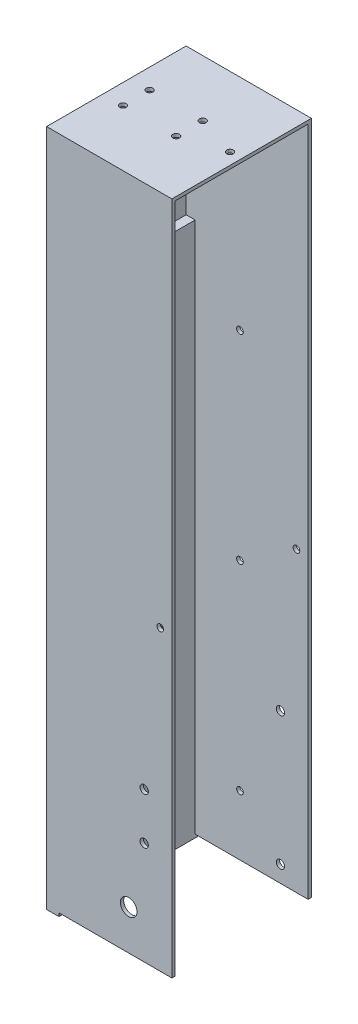
from build123d import *

# Parameters (mm, degrees)
SKETCH1_W            = 42
SKETCH1_H            = 170
BOSS_EXTRUDE1_DEPTH  = 1
SKETCH2_W            = 1
SKETCH2_H            = 170
BOSS_EXTRUDE2_DEPTH  = 50
BOSS_EXTRUDE3_DEPTH  = 30
SKETCH5_W            = 1
SKETCH5_H            = 1
CUT_EXTRUDE1_DEPTH   = 170
SKETCH6_W            = 1
SKETCH6_H            = 1
CUT_EXTRUDE2_DEPTH   = 170
SKETCH9_R            = 1.5
CUT_EXTRUDE3_DEPTH   = 10
SKETCH10_R           = 1.5
CUT_EXTRUDE4_DEPTH   = 10
SKETCH11_R           = 2.028327886
BOSS_EXTRUDE4_DEPTH  = 1
SKETCH13_W           = 40
SKETCH13_H           = 22.9
BOSS_EXTRUDE5_DEPTH  = 50
SKETCH14_W           = 42
SKETCH14_H           = 21.9
CUT_EXTRUDE6_DEPTH   = 60
SKETCH17_R           = 1
CUT_EXTRUDE7_DEPTH   = 10
SKETCH18_W           = 40
SKETCH18_H           = 1
SKETCH18_W_2         = 36
SKETCH18_W_3         = 13
SKETCH18_W_4         = 9
BOSS_EXTRUDE7_DEPTH  = 1
SKETCH19_W           = 1
SKETCH19_H           = 42
BOSS_EXTRUDE8_DEPTH  = 1
SKETCH20_W           = 1.000149207
SKETCH20_H           = 1
CUT_EXTRUDE8_DEPTH   = 1
SKETCH21_W           = 1
SKETCH21_H           = 1
CUT_EXTRUDE9_DEPTH   = 1
BOSS_EXTRUDE9_REACH  = 44
SKETCH22_W           = 1
SKETCH22_H           = 31
SKETCH26_W           = 11.5
SKETCH26_H           = 42
BOSS_EXTRUDE13_DEPTH = 1
SKETCH35_W           = 40
SKETCH35_H           = 31
CUT_EXTRUDE17_DEPTH  = 27
SKETCH36_W           = 42
SKETCH36_H           = 1
CUT_EXTRUDE18_DEPTH  = 24
SKETCH37_W           = 12
SKETCH37_H           = 212.744224338
CUT_EXTRUDE19_DEPTH  = 50
SKETCH39_R           = 1.25
CUT_EXTRUDE20_DEPTH  = 10
SKETCH40_R           = 1.25
CUT_EXTRUDE21_DEPTH  = 10
SKETCH41_R           = 2.590750915
BOSS_EXTRUDE14_DEPTH = 1
SKETCH42_R           = 1.25
CUT_EXTRUDE22_DEPTH  = 1
SKETCH43_R           = 1.25
CUT_EXTRUDE23_DEPTH  = 1
SKETCH44_R           = 6.392169631
BOSS_EXTRUDE16_DEPTH = 1
SKETCH45_R           = 1.25
CUT_EXTRUDE24_DEPTH  = 1
SKETCH46_W           = 1.29
SKETCH46_H           = 42
CUT_EXTRUDE25_DEPTH  = 190
SKETCH47_W           = 1
SKETCH47_H           = 42
BOSS_EXTRUDE17_DEPTH = 179.1
SKETCH48_W           = 37.71
SKETCH48_H           = 0.1
CUT_EXTRUDE26_DEPTH  = 179.1
SKETCH50_W           = 10
SKETCH50_H           = 120
BOSS_EXTRUDE20_DEPTH = 4
SKETCH52_W           = 28
SKETCH52_H           = 1
SKETCH52_W_2         = 24
BOSS_EXTRUDE21_DEPTH = 0.1
BOSS_EXTRUDE22_DEPTH = 0.1
SKETCH54_W           = 10
SKETCH54_H           = 120.1
BOSS_EXTRUDE23_DEPTH = 3.71
SKETCH55_W           = 4.2
SKETCH55_H           = 42
BOSS_EXTRUDE24_DEPTH = 1
SKETCH56_W           = 0.49
SKETCH56_H           = 42
CUT_EXTRUDE27_DEPTH  = 1
SKETCH58_R           = 1
CUT_EXTRUDE28_DEPTH  = 1
SKETCH59_R           = 1.868831557
BOSS_EXTRUDE25_DEPTH = 1
SKETCH60_R           = 1
CUT_EXTRUDE29_DEPTH  = 1
SKETCH61_R           = 1
CUT_EXTRUDE30_DEPTH  = 1
SKETCH62_W           = 5.426939544
SKETCH62_H           = 172.64225577
BOSS_EXTRUDE26_DEPTH = 1
SKETCH63_W           = 5.574315559
SKETCH63_H           = 175.575200823
BOSS_EXTRUDE27_DEPTH = 1
SKETCH64_W           = 3.71
SKETCH64_H           = 42
BOSS_EXTRUDE29_DEPTH = 121.1
SKETCH66_R           = 1
CUT_EXTRUDE31_DEPTH  = 43
SKETCH67_R           = 1
CUT_EXTRUDE32_DEPTH  = 1
SKETCH68_R           = 2.5
CUT_EXTRUDE33_DEPTH  = 10
SKETCH71_R           = 1
CUT_EXTRUDE35_DEPTH  = 10
SKETCH72_W           = 37.71
SKETCH72_H           = 20
BOSS_EXTRUDE30_DEPTH = 42
SKETCH73_R           = 1
CUT_EXTRUDE36_DEPTH  = 42
SKETCH74_W           = 40
SKETCH74_H           = 20
CUT_EXTRUDE38_DEPTH  = 36.71
SKETCH75_W           = 37.71
SKETCH75_H           = 4
BOSS_EXTRUDE31_DEPTH = 42
SKETCH76_R           = 1
CUT_EXTRUDE39_DEPTH  = 42
SKETCH77_W           = 40
SKETCH77_H           = 4
CUT_EXTRUDE40_DEPTH  = 36.71
BOSS_EXTRUDE32_DEPTH = 40
CUT_EXTRUDE41_DEPTH  = 5
CUT_EXTRUDE42_DEPTH  = 5
SKETCH81_R           = 1
CUT_EXTRUDE43_DEPTH  = 9.71
SKETCH82_R           = 1
CUT_EXTRUDE44_DEPTH  = 9.71


with BuildPart() as part:
    # Sketch1 → Boss-Extrude1 (new body)
    with BuildSketch(Plane(origin=(0, 0, 0), x_dir=(0, 0, -1), z_dir=(1, 0, 0))):
        with Locations((7.169014085, -74.911791253)):
            Rectangle(SKETCH1_W, SKETCH1_H)
    extrude(amount=BOSS_EXTRUDE1_DEPTH)

    # Sketch2 → Boss-Extrude2 (add)
    with BuildSketch(Plane(origin=(1, 0, 0), x_dir=(0, 0, -1), z_dir=(1, 0, 0))):
        with Locations((27.669014085, -74.911791253)):
            Rectangle(SKETCH2_W, SKETCH2_H)
        with Locations((-13.330985915, -74.911791253)):
            Rectangle(SKETCH2_W, SKETCH2_H)
    extrude(amount=BOSS_EXTRUDE2_DEPTH)

    # Sketch4 → Boss-Extrude3 (add)
    with BuildSketch(Plane(origin=(0, 10.088208747, 0), x_dir=(1, 0, 0), z_dir=(0, 1, 0))):
        Polygon((51, 28.169014085), (51, 27.169014085), (1, 27.169014085), (1, -12.830985915), (51, -12.830985915), (51, -13.830985915), (0, -13.830985915), (0, 28.169014085), align=None)
    extrude(amount=BOSS_EXTRUDE3_DEPTH)

    # Sketch5 → Cut-Extrude1 (cut)
    with BuildSketch(Plane.XZ.offset(159.911791253)):
        with Locations((10.5, 13.330985915)):
            Rectangle(SKETCH5_W, SKETCH5_H)
    extrude(amount=-CUT_EXTRUDE1_DEPTH, mode=Mode.SUBTRACT)

    # Sketch6 → Cut-Extrude2 (cut)
    with BuildSketch(Plane.XZ.offset(159.911791253)):
        with Locations((14.5, -27.669014085)):
            Rectangle(SKETCH6_W, SKETCH6_H)
    extrude(amount=-CUT_EXTRUDE2_DEPTH, mode=Mode.SUBTRACT)

    # Sketch9 → Cut-Extrude3 (cut)
    with BuildSketch(Plane.XY.offset(13.830985915)):
        with Locations((26, -144.911791253)):
            Circle(SKETCH9_R)
    extrude(amount=-CUT_EXTRUDE3_DEPTH, mode=Mode.SUBTRACT)

    # Sketch10 → Cut-Extrude4 (cut)
    with BuildSketch(Plane.XY.offset(13.830985915)):
        with Locations((26, -148.911791253)):
            Circle(SKETCH10_R)
    extrude(amount=-CUT_EXTRUDE4_DEPTH, mode=Mode.SUBTRACT)

    # Sketch11 → Boss-Extrude4 (add)
    with BuildSketch(Plane.XY.offset(13.830985915)):
        with Locations((26, -144.911791253)):
            Circle(SKETCH11_R)
    extrude(amount=-BOSS_EXTRUDE4_DEPTH)

    # Sketch13 → Boss-Extrude5 (add)
    with BuildSketch(Plane(origin=(1, 0, 0), x_dir=(0, 0, -1), z_dir=(1, 0, 0))):
        with Locations((7.169014085, 28.638208747)):
            Rectangle(SKETCH13_W, SKETCH13_H)
    extrude(amount=BOSS_EXTRUDE5_DEPTH)

    # Sketch14 → Cut-Extrude6 (cut)
    with BuildSketch(Plane(origin=(51, 0, 0), x_dir=(0, 0, -1), z_dir=(1, 0, 0))):
        with Locations((7.169014085, 29.138208747)):
            Rectangle(SKETCH14_W, SKETCH14_H)
    extrude(amount=-CUT_EXTRUDE6_DEPTH, mode=Mode.SUBTRACT)

    # Sketch17 → Cut-Extrude7 (cut)
    with BuildSketch(Plane.XZ.offset(-17.188208747)):
        with Locations((23.29, -11.169014085)):
            Circle(SKETCH17_R)
        with Locations((23.29, -3.169014085)):
            Circle(SKETCH17_R)
        with Locations((7.29, -11.169014085)):
            Circle(SKETCH17_R)
        with Locations((7.29, -3.169014085)):
            Circle(SKETCH17_R)
    extrude(amount=-CUT_EXTRUDE7_DEPTH, mode=Mode.SUBTRACT)

    # Sketch18 → Boss-Extrude7 (add)
    with BuildSketch(Plane.XZ.offset(159.911791253)):
        with Locations((31, 13.330985915)):
            Rectangle(SKETCH18_W, SKETCH18_H)
        with Locations((33, -27.669014085)):
            Rectangle(SKETCH18_W_2, SKETCH18_H)
        with Locations((7.5, -27.669014085)):
            Rectangle(SKETCH18_W_3, SKETCH18_H)
        with Locations((5.5, 13.330985915)):
            Rectangle(SKETCH18_W_4, SKETCH18_H)
    extrude(amount=BOSS_EXTRUDE7_DEPTH)

    # Sketch19 → Boss-Extrude8 (add)
    with BuildSketch(Plane.XZ.offset(159.911791253)):
        with Locations((0.5, -7.169014085)):
            Rectangle(SKETCH19_W, SKETCH19_H)
    extrude(amount=BOSS_EXTRUDE8_DEPTH)

    # Sketch20 → Cut-Extrude8 (cut)
    with BuildSketch(Plane(origin=(0, 0, -28.169014085), x_dir=(-1, 0, 0), z_dir=(0, 0, -1))):
        with Locations((-14.499925397, 10.588208747)):
            Rectangle(SKETCH20_W, SKETCH20_H)
    extrude(amount=-CUT_EXTRUDE8_DEPTH, mode=Mode.SUBTRACT)

    # Sketch21 → Cut-Extrude9 (cut)
    with BuildSketch(Plane.XY.offset(13.830985915)):
        with Locations((10.5, 10.588208747)):
            Rectangle(SKETCH21_W, SKETCH21_H)
    extrude(amount=-CUT_EXTRUDE9_DEPTH, mode=Mode.SUBTRACT)

    # Sketch22 → Boss-Extrude9 (add, up to next)
    with BuildSketch(Plane.XY.offset(13.830985915), mode=Mode.PRIVATE) as boss_extrude9_sk1:
        with Locations((38.5, -145.411791253)):
            Rectangle(SKETCH22_W, SKETCH22_H)
    boss_extrude9_tool1 = extrude(boss_extrude9_sk1.sketch, amount=-BOSS_EXTRUDE9_REACH, mode=Mode.PRIVATE) - part.part
    add(boss_extrude9_tool1.solids().sort_by_distance((38.5, -145.411791, 13.830986))[0])

    # Sketch26 → Boss-Extrude13 (add)
    with BuildSketch(Plane(origin=(0, -160.911791253, 0), x_dir=(-1, 0, 0), z_dir=(0, -1, 0))):
        with Locations((-22.127481667, 7.169014085)):
            Rectangle(SKETCH26_W, SKETCH26_H)
    extrude(amount=BOSS_EXTRUDE13_DEPTH)

    # Sketch35 → Cut-Extrude17 (cut)
    with BuildSketch(Plane(origin=(39, 0, 0), x_dir=(0, 0, -1), z_dir=(1, 0, 0))):
        with Locations((7.169014085, -145.411791253)):
            Rectangle(SKETCH35_W, SKETCH35_H)
    extrude(amount=-CUT_EXTRUDE17_DEPTH, mode=Mode.SUBTRACT)

    # Sketch36 → Cut-Extrude18 (cut)
    with BuildSketch(Plane(origin=(27.877481667, 0, 0), x_dir=(0, 0, -1), z_dir=(1, 0, 0))):
        with Locations((7.169014085, -161.411791253)):
            Rectangle(SKETCH36_W, SKETCH36_H)
    extrude(amount=-CUT_EXTRUDE18_DEPTH, mode=Mode.SUBTRACT)

    # Sketch37 → Cut-Extrude19 (cut)
    with BuildSketch(Plane.XY.offset(13.830985915)):
        with Locations((45, -54.539679084)):
            Rectangle(SKETCH37_W, SKETCH37_H)
    extrude(amount=-CUT_EXTRUDE19_DEPTH, mode=Mode.SUBTRACT)

    # Sketch39 → Cut-Extrude20 (cut)
    with BuildSketch(Plane(origin=(0, 0, -28.169014085), x_dir=(-1, 0, 0), z_dir=(0, 0, -1))):
        with Locations((-30.67, -155.911791253)):
            Circle(SKETCH39_R)
    extrude(amount=-CUT_EXTRUDE20_DEPTH, mode=Mode.SUBTRACT)

    # Sketch40 → Cut-Extrude21 (cut)
    with BuildSketch(Plane(origin=(0, 0, -28.169014085), x_dir=(-1, 0, 0), z_dir=(0, 0, -1))):
        with Locations((-30.67, -129.911791253)):
            Circle(SKETCH40_R)
    extrude(amount=-CUT_EXTRUDE21_DEPTH, mode=Mode.SUBTRACT)

    # Sketch41 → Boss-Extrude14 (add)
    with BuildSketch(Plane(origin=(0, 0, -28.169014085), x_dir=(-1, 0, 0), z_dir=(0, 0, -1))):
        with Locations((-30.67, -129.911791253)):
            Circle(SKETCH41_R)
    extrude(amount=-BOSS_EXTRUDE14_DEPTH)

    # Sketch42 → Cut-Extrude22 (cut)
    with BuildSketch(Plane(origin=(0, 0, -28.169014085), x_dir=(-1, 0, 0), z_dir=(0, 0, -1))):
        with Locations((-30.67, -115.911791253)):
            Circle(SKETCH42_R)
    extrude(amount=-CUT_EXTRUDE22_DEPTH, mode=Mode.SUBTRACT)

    # Sketch43 → Cut-Extrude23 (cut)
    with BuildSketch(Plane.XY.offset(13.830985915)):
        with Locations((30.67, -128.911791253)):
            Circle(SKETCH43_R)
        with Locations((30.67, -115.911791253)):
            Circle(SKETCH43_R)
    extrude(amount=-CUT_EXTRUDE23_DEPTH, mode=Mode.SUBTRACT)

    # Sketch44 → Boss-Extrude16 (add)
    with BuildSketch(Plane.XY.offset(13.830985915)):
        with Locations((27.109567227, -127.276171825)):
            Circle(SKETCH44_R)
    extrude(amount=-BOSS_EXTRUDE16_DEPTH)

    # Sketch45 → Cut-Extrude24 (cut)
    with BuildSketch(Plane.XY.offset(13.830985915)):
        with Locations((30.67, -129.911791253)):
            Circle(SKETCH45_R)
    extrude(amount=-CUT_EXTRUDE24_DEPTH, mode=Mode.SUBTRACT)

    # Sketch46 → Cut-Extrude25 (cut)
    with BuildSketch(Plane(origin=(0, 18.188208747, 0), x_dir=(1, 0, 0), z_dir=(0, 1, 0))):
        with Locations((0.645, 7.169014085)):
            Rectangle(SKETCH46_W, SKETCH46_H)
    extrude(amount=-CUT_EXTRUDE25_DEPTH, mode=Mode.SUBTRACT)

    # Sketch47 → Boss-Extrude17 (add)
    with BuildSketch(Plane(origin=(0, 18.188208747, 0), x_dir=(1, 0, 0), z_dir=(0, 1, 0))):
        with Locations((1.79, 7.169014085)):
            Rectangle(SKETCH47_W, SKETCH47_H)
    extrude(amount=-BOSS_EXTRUDE17_DEPTH)

    # Sketch48 → Cut-Extrude26 (cut)
    with BuildSketch(Plane(origin=(0, 0, -28.169014085), x_dir=(-1, 0, 0), z_dir=(0, 0, -1))):
        with Locations((-20.145, -160.861791253)):
            Rectangle(SKETCH48_W, SKETCH48_H)
    extrude(amount=-CUT_EXTRUDE26_DEPTH, mode=Mode.SUBTRACT)

    # Sketch50 → Boss-Extrude20 (add)
    with BuildSketch(Plane(origin=(2.29, 0, 0), x_dir=(0, 0, -1), z_dir=(1, 0, 0))):
        with Locations((7.169014085, -100.811791253)):
            Rectangle(SKETCH50_W, SKETCH50_H)
    extrude(amount=BOSS_EXTRUDE20_DEPTH)

    # Sketch52 → Boss-Extrude21 (add)
    with BuildSketch(Plane.XZ.offset(160.811791253)):
        with Locations((25, 13.330985915)):
            Rectangle(SKETCH52_W, SKETCH52_H)
        with Locations((27, -27.669014085)):
            Rectangle(SKETCH52_W_2, SKETCH52_H)
    extrude(amount=BOSS_EXTRUDE21_DEPTH)

    # Sketch53 → Boss-Extrude22 (add)
    with BuildSketch(Plane(origin=(0, -160.811791253, 0), x_dir=(-1, 0, 0), z_dir=(0, -1, 0))):
        Polygon((-10, -13.830985915), (-10, -12.830985915), (-2.29, -12.830985915), (-2.29, 2.169014085), (-6.29, 2.169014085), (-6.29, 12.169014085), (-2.29, 12.169014085), (-2.29, 27.169014085), (-13.999850793, 27.169014085), (-14, 28.169014085), (-1.29, 28.169014085), (-1.29, -13.830985915), align=None)
    extrude(amount=BOSS_EXTRUDE22_DEPTH)

    # Sketch54 → Boss-Extrude23 (add)
    with BuildSketch(Plane(origin=(6.29, 0, 0), x_dir=(0, 0, -1), z_dir=(1, 0, 0))):
        with Locations((7.169014085, -100.861791253)):
            Rectangle(SKETCH54_W, SKETCH54_H)
    extrude(amount=BOSS_EXTRUDE23_DEPTH)

    # Sketch55 → Boss-Extrude24 (add)
    with BuildSketch(Plane.XZ.offset(160.911791253)):
        with Locations((3.39, -7.169014085)):
            Rectangle(SKETCH55_W, SKETCH55_H)
    extrude(amount=BOSS_EXTRUDE24_DEPTH)

    # Sketch56 → Cut-Extrude27 (cut)
    with BuildSketch(Plane.XZ.offset(161.911791253)):
        with Locations((5.245, -7.169014085)):
            Rectangle(SKETCH56_W, SKETCH56_H)
    extrude(amount=-CUT_EXTRUDE27_DEPTH, mode=Mode.SUBTRACT)

    # Sketch58 → Cut-Extrude28 (cut)
    with BuildSketch(Plane(origin=(0, 0, -28.169014085), x_dir=(-1, 0, 0), z_dir=(0, 0, -1))):
        with Locations((-17.5, -22.811791253)):
            Circle(SKETCH58_R)
    extrude(amount=-CUT_EXTRUDE28_DEPTH, mode=Mode.SUBTRACT)

    # Sketch59 → Boss-Extrude25 (add)
    with BuildSketch(Plane(origin=(0, 0, -28.169014085), x_dir=(-1, 0, 0), z_dir=(0, 0, -1))):
        with Locations((-17.5, -22.811791253)):
            Circle(SKETCH59_R)
    extrude(amount=-BOSS_EXTRUDE25_DEPTH)

    # Sketch60 → Cut-Extrude29 (cut)
    with BuildSketch(Plane(origin=(0, 0, -28.169014085), x_dir=(-1, 0, 0), z_dir=(0, 0, -1))):
        with Locations((-18.5, -22.811791253)):
            Circle(SKETCH60_R)
    extrude(amount=-CUT_EXTRUDE29_DEPTH, mode=Mode.SUBTRACT)

    # Sketch61 → Cut-Extrude30 (cut)
    with BuildSketch(Plane(origin=(0, 0, -28.169014085), x_dir=(-1, 0, 0), z_dir=(0, 0, -1))):
        with Locations((-18.5, -82.811791253)):
            Circle(SKETCH61_R)
    extrude(amount=-CUT_EXTRUDE30_DEPTH, mode=Mode.SUBTRACT)

    # Sketch62 → Boss-Extrude26 (add)
    with BuildSketch(Plane(origin=(0, 0, -28.169014085), x_dir=(-1, 0, 0), z_dir=(0, 0, -1))):
        with Locations((-13.713469772, -74.590663368)):
            Rectangle(SKETCH62_W, SKETCH62_H)
    extrude(amount=-BOSS_EXTRUDE26_DEPTH)

    # Sketch63 → Boss-Extrude27 (add)
    with BuildSketch(Plane.XY.offset(13.830985915)):
        with Locations((11.581123443, -73.124190842)):
            Rectangle(SKETCH63_W, SKETCH63_H)
    extrude(amount=-BOSS_EXTRUDE27_DEPTH)

    # Sketch64 → Boss-Extrude29 (add)
    with BuildSketch(Plane.XZ.offset(161.911791253)):
        with Locations((3.145, -7.169014085)):
            Rectangle(SKETCH64_W, SKETCH64_H)
    extrude(amount=-BOSS_EXTRUDE29_DEPTH)

    # Sketch66 → Cut-Extrude31 (cut, through all)
    with BuildSketch(Plane(origin=(0, 0, -28.169014085), x_dir=(-1, 0, 0), z_dir=(0, 0, -1))):
        with Locations((-35.5, -71.361791253)):
            Circle(SKETCH66_R)
    extrude(amount=-CUT_EXTRUDE31_DEPTH, mode=Mode.SUBTRACT)

    # Sketch67 → Cut-Extrude32 (cut)
    with BuildSketch(Plane(origin=(0, 18.188208747, 0), x_dir=(1, 0, 0), z_dir=(0, 1, 0))):
        with Locations((35.5, 7.169014085)):
            Circle(SKETCH67_R)
    extrude(amount=-CUT_EXTRUDE32_DEPTH, mode=Mode.SUBTRACT)

    # Sketch68 → Cut-Extrude33 (cut)
    with BuildSketch(Plane.XY.offset(13.830985915)):
        with Locations((26, -148.911791253)):
            Circle(SKETCH68_R)
    extrude(amount=-CUT_EXTRUDE33_DEPTH, mode=Mode.SUBTRACT)

    # Sketch71 → Cut-Extrude35 (cut)
    with BuildSketch(Plane(origin=(0, 0, -28.169014085), x_dir=(-1, 0, 0), z_dir=(0, 0, -1))):
        with Locations((-18.5, -142.811791253)):
            Circle(SKETCH71_R)
    extrude(amount=-CUT_EXTRUDE35_DEPTH, mode=Mode.SUBTRACT)

    # Sketch72 → Boss-Extrude30 (add)
    with BuildSketch(Plane(origin=(0, 0, -28.169014085), x_dir=(-1, 0, 0), z_dir=(0, 0, -1))):
        with Locations((-20.145, 28.188208747)):
            Rectangle(SKETCH72_W, SKETCH72_H)
    extrude(amount=-BOSS_EXTRUDE30_DEPTH)

    # Sketch73 → Cut-Extrude36 (cut)
    with BuildSketch(Plane.XZ.offset(-17.188208747)):
        with Locations((7.29, -3.169014085)):
            Circle(SKETCH73_R)
        with Locations((23.29, -3.169014085)):
            Circle(SKETCH73_R)
        with Locations((35.5, -7.169014085)):
            Circle(SKETCH73_R)
        with Locations((23.29, -11.169014085)):
            Circle(SKETCH73_R)
        with Locations((7.29, -11.169014085)):
            Circle(SKETCH73_R)
    extrude(amount=-CUT_EXTRUDE36_DEPTH, mode=Mode.SUBTRACT)

    # Sketch74 → Cut-Extrude38 (cut)
    with BuildSketch(Plane(origin=(39, 0, 0), x_dir=(0, 0, -1), z_dir=(1, 0, 0))):
        with Locations((7.169014085, 27.188208747)):
            Rectangle(SKETCH74_W, SKETCH74_H)
    extrude(amount=-CUT_EXTRUDE38_DEPTH, mode=Mode.SUBTRACT)

    # Sketch75 → Boss-Extrude31 (add)
    with BuildSketch(Plane(origin=(0, 0, -28.169014085), x_dir=(-1, 0, 0), z_dir=(0, 0, -1))):
        with Locations((-20.145, 40.188208747)):
            Rectangle(SKETCH75_W, SKETCH75_H)
    extrude(amount=-BOSS_EXTRUDE31_DEPTH)

    # Sketch76 → Cut-Extrude39 (cut)
    with BuildSketch(Plane.XZ.offset(-37.188208747)):
        with Locations((35.5, -7.169014085)):
            Circle(SKETCH76_R)
        with Locations((23.29, -3.169014085)):
            Circle(SKETCH76_R)
        with Locations((23.29, -11.169014085)):
            Circle(SKETCH76_R)
        with Locations((7.29, -3.169014085)):
            Circle(SKETCH76_R)
        with Locations((7.29, -11.169014085)):
            Circle(SKETCH76_R)
    extrude(amount=-CUT_EXTRUDE39_DEPTH, mode=Mode.SUBTRACT)

    # Sketch77 → Cut-Extrude40 (cut)
    with BuildSketch(Plane(origin=(39, 0, 0), x_dir=(0, 0, -1), z_dir=(1, 0, 0))):
        with Locations((7.169014085, 39.188208747)):
            Rectangle(SKETCH77_W, SKETCH77_H)
    extrude(amount=-CUT_EXTRUDE40_DEPTH, mode=Mode.SUBTRACT)

    # Sketch78 → Boss-Extrude32 (add)
    with BuildSketch(Plane(origin=(0, -40.811791253, 0), x_dir=(1, 0, 0), z_dir=(0, 1, 0))):
        Polygon((10, 2.169014085), (5, 2.169014085), (5, -12.830985915), (2.29, -12.830985915), (2.29, 27.169014085), (5, 27.169014085), (5, 12.169014085), (10, 12.169014085), align=None)
    extrude(amount=BOSS_EXTRUDE32_DEPTH)

    # Sketch79 → Cut-Extrude41 (cut)
    with BuildSketch(Plane(origin=(10, 0, 0), x_dir=(0, 0, -1), z_dir=(1, 0, 0))):
        Polygon((8.323714623, -17.811791253), (9.478415161, -15.811791253), (8.323714623, -13.811791253), (6.014313546, -13.811791253), (4.859613008, -15.811791253), (6.014313546, -17.811791253), align=None)
    extrude(amount=-CUT_EXTRUDE41_DEPTH, mode=Mode.SUBTRACT)

    # Sketch80 → Cut-Extrude42 (cut)
    with BuildSketch(Plane(origin=(10, 0, 0), x_dir=(0, 0, -1), z_dir=(1, 0, 0))):
        Polygon((8.323714623, -142.041098915), (9.478415161, -140.041098915), (8.323714623, -138.041098915), (6.014313546, -138.041098915), (4.859613008, -140.041098915), (6.014313546, -142.041098915), align=None)
    extrude(amount=-CUT_EXTRUDE42_DEPTH, mode=Mode.SUBTRACT)

    # Sketch81 → Cut-Extrude43 (cut, through all)
    with BuildSketch(Plane(origin=(10, 0, 0), x_dir=(0, 0, -1), z_dir=(1, 0, 0))):
        with Locations((7.169014085, -15.811791253)):
            Circle(SKETCH81_R)
    extrude(amount=-CUT_EXTRUDE43_DEPTH, mode=Mode.SUBTRACT)

    # Sketch82 → Cut-Extrude44 (cut, through all)
    with BuildSketch(Plane(origin=(10, 0, 0), x_dir=(0, 0, -1), z_dir=(1, 0, 0))):
        with Locations((7.169014085, -140.041098915)):
            Circle(SKETCH82_R)
    extrude(amount=-CUT_EXTRUDE44_DEPTH, mode=Mode.SUBTRACT)


solid = part.part
